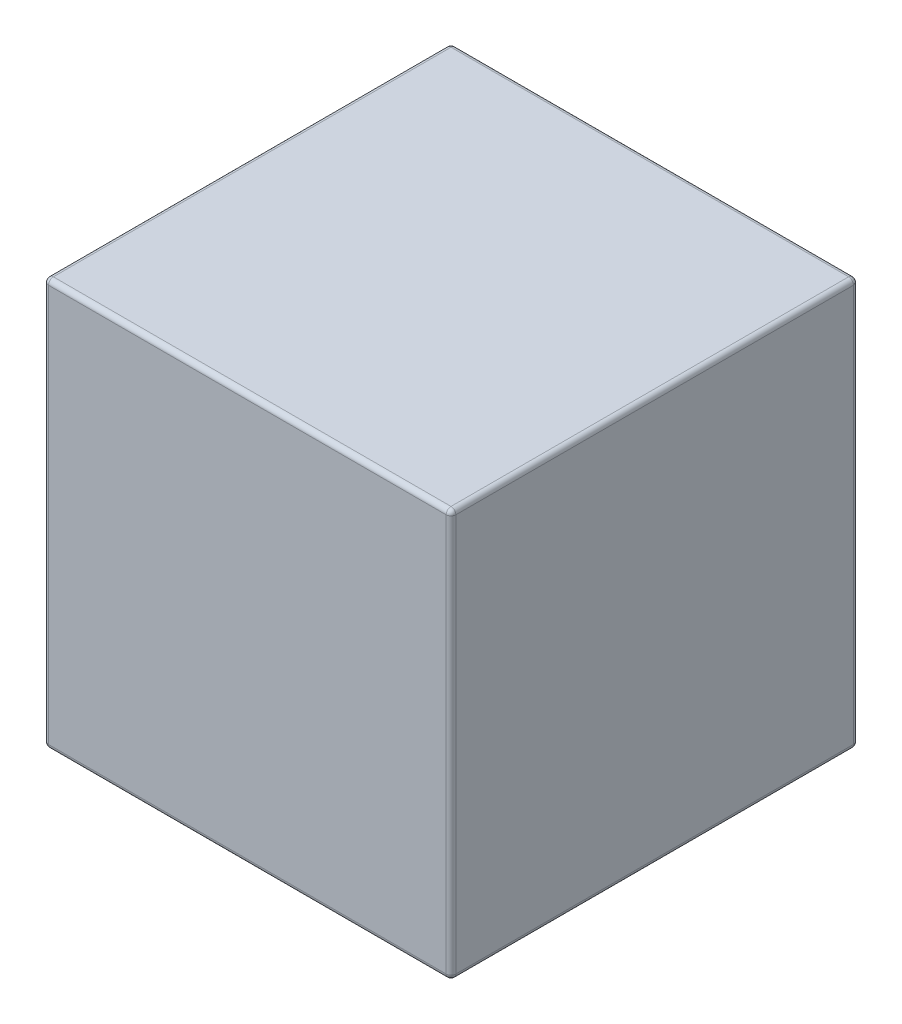
from build123d import *

# Parameters (mm, degrees)
SKETCH_1_W      = 42
SKETCH_1_H      = 42
EXTRUDE_1_DEPTH = 42
FILLET_1_R      = 0.5


with BuildPart() as part:
    # 草图1 → 凸台-拉伸1 (new body)
    with BuildSketch(Plane.XY):
        Rectangle(SKETCH_1_W, SKETCH_1_H)
    extrude(amount=EXTRUDE_1_DEPTH)

    # 圆角1
    fillet_1_edges = [part.edges().sort_by_distance(p)[0] for p in [
        (21, 0, 42),
        (0, 21, 42),
        (-21, 0, 42),
        (0, 21, 0),
        (21, 0, 0),
        (0, -21, 0),
        (-21, 0, 0),
        (0, -21, 42),
        (-21, 21, 21),
        (21, 21, 21),
        (21, -21, 21),
        (-21, -21, 21),
    ]]
    fillet(fillet_1_edges, radius=FILLET_1_R)


solid = part.part
